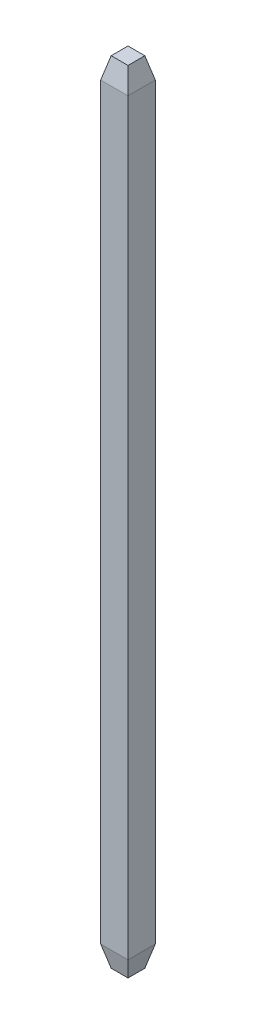
from build123d import *

# Parameters (mm, degrees)
SKETCH1_W           = 0.65
SKETCH1_H           = 0.65
BOSS_EXTRUDE1_DEPTH = 9.4
CUT_EXTRUDE1_REACH  = 20.306
SKETCH3_W           = 0.65
SKETCH3_H           = 0.65


with BuildPart() as part:
    # Sketch1 → Boss-Extrude1 (new, symmetric)
    with BuildSketch(Plane(origin=(0, 0, 0), x_dir=(1, 0, 0), z_dir=(0, 1, 0))):
        Rectangle(SKETCH1_W, SKETCH1_H)
    extrude(amount=BOSS_EXTRUDE1_DEPTH, both=True)

    # Sketch3 → Cut-Extrude1 (cut, up to next)
    with BuildSketch(Plane(origin=(0, 8.9, 0), x_dir=(1, 0, 0), z_dir=(0, 1, 0)), mode=Mode.PRIVATE) as cut_extrude1_sk1:
        Rectangle(SKETCH3_W, SKETCH3_H)
    cut_extrude1_tool1 = extrude(cut_extrude1_sk1.sketch, amount=CUT_EXTRUDE1_REACH, mode=Mode.PRIVATE) & part.part
    cut_extrude1 = cut_extrude1_tool1.solids().sort_by_distance((0, 8.9, 0))[0]
    add(cut_extrude1, mode=Mode.SUBTRACT)

    # Sketch3_3 → Loft1 section 0
    with BuildSketch(Plane(origin=(0, 8.9, 0), x_dir=(1, 0, 0), z_dir=(0, 1, 0))):
        with BuildLine():
            Line((0.325, -0.325), (-0.325, -0.325))
            Line((-0.325, -0.325), (-0.325, 0.325))
            Line((-0.325, 0.325), (0.325, 0.325))
            Line((0.325, 0.325), (0.325, -0.325))
        make_face()
    # Sketch2 → Loft1 section 1
    with BuildSketch(Plane(origin=(0, 9.4, 0), x_dir=(1, 0, 0), z_dir=(0, 1, 0))):
        with BuildLine():
            Line((-0.2, -0.2), (0.2, -0.2))
            Line((0.2, -0.2), (0.2, 0.2))
            Line((0.2, 0.2), (-0.2, 0.2))
            Line((-0.2, 0.2), (-0.2, -0.2))
        make_face()
    loft1 = loft()

    # Mirror1: Cut-Extrude1, Loft1 across plane
    add(cut_extrude1.mirror(Plane.ZX), mode=Mode.SUBTRACT)
    add(loft1.mirror(Plane.ZX))


solid = part.part
